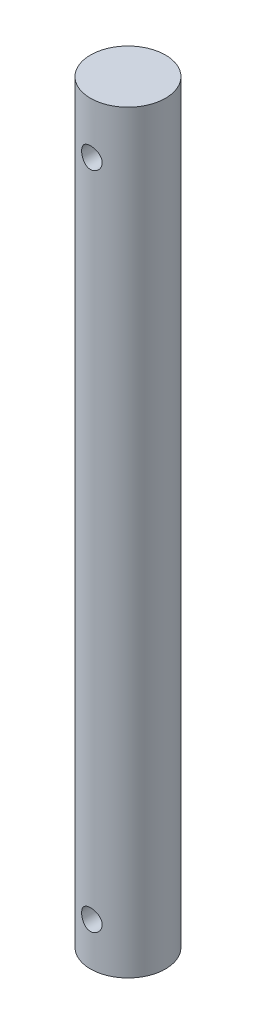
from build123d import *

# Parameters (mm, degrees)
SKETCH1_R                  = 5.55625
BOSS_EXTRUDE1_DEPTH        = 111.76
F_31_0_12_DIAMETER_HOLE1_D = 3.048


with BuildPart() as part:
    # Sketch1 → Boss-Extrude1 (new body)
    with BuildSketch(Plane(origin=(0, 0, 0), x_dir=(1, 0, 0), z_dir=(0, 1, 0))):
        Circle(SKETCH1_R)
    extrude(amount=BOSS_EXTRUDE1_DEPTH)

    # #31 (0.12) Diameter Hole1 (through all)
    with Locations(Plane.XY.offset(5.55625)):
        with Locations((0, 104.14), (0, 6.35)):
            Hole(F_31_0_12_DIAMETER_HOLE1_D / 2)


solid = part.part
